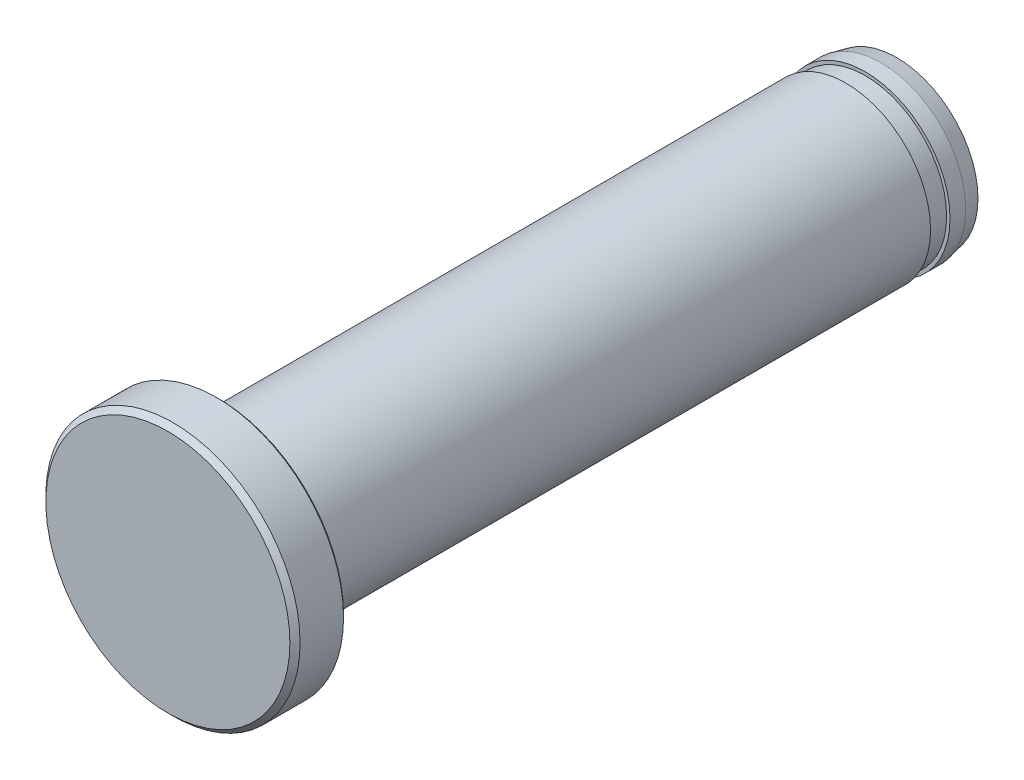
from build123d import *


with BuildPart() as part:
    # 草图3 → 旋转1 (revolve)
    with BuildSketch(Plane(origin=(0, 0, 0), x_dir=(0, 0, -1), z_dir=(1, 0, 0)), mode=Mode.PRIVATE) as revolve_1_sk:
        with BuildLine():
            Line((18.5, 0), (21.5, 0))
            Line((21.5, 0), (21.5, 4.8))
            Line((21.5, 4.8), (20.575, 5))
            Line((20.575, 5), (19.65, 5))
            Line((19.65, 5), (19.65, 4.8))
            Line((19.65, 4.8), (18.5, 4.8))
            Line((18.5, 4.8), (18.5, 5))
            Line((18.5, 5), (0, 5))
            Line((0, 5), (-18.333333333, 5))
            ThreePointArc((-18.333333333, 5), (-18.451184464, 5.048815536), (-18.5, 5.166666667))
            Line((-18.5, 5.166666667), (-18.5, 7.366666667))
            Line((-18.5, 7.366666667), (-18.633333333, 7.5))
            Line((-18.633333333, 7.5), (-21.2, 7.5))
            Line((-21.2, 7.5), (-21.5, 7.2))
            Line((-21.5, 7.2), (-21.5, 0))
            Line((-21.5, 0), (18.5, 0))
        make_face()
    revolve(revolve_1_sk.sketch.rotate(Axis((0, 0, 21.5), (0, 0, -1)), 90), axis=Axis((0, 0, 21.5), (0, 0, -1)))


solid = part.part
